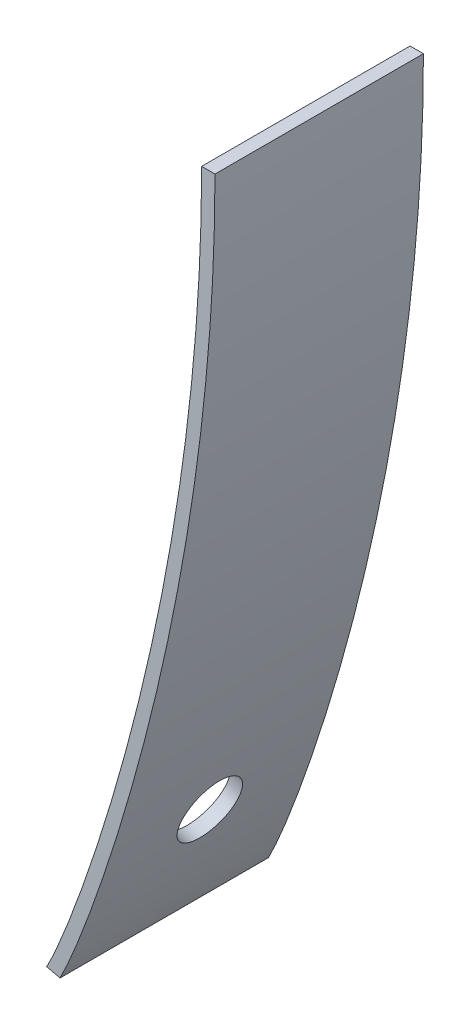
from build123d import *

# Parameters (mm, degrees)
BOSS_EXTRUDE1_DEPTH = 15.875
SKETCH3_R           = 2.38125
CUT_EXTRUDE1_DEPTH  = 22.710547331


with BuildPart() as part:
    # Sketch1 → Boss-Extrude1 (new body)
    with BuildSketch(Plane.XY):
        with BuildLine():
            Line((-1.016, 29.355277439), (0, 29.355277439))
            add(Edge.make_bspline(
                [(0, 29.355277439), (0, 0), (-9.599644928, -25.418345845), (-11.80014336, -29.574736835)],
                knots=[0, 0, 0, 0, 1, 1, 1, 1], degree=3))
            Line((-11.80014336, -29.574736835), (-12.82390686, -29.337045136))
            Line((-12.82390686, -29.337045136), (-12.698066868, -29.099353437))
            add(Edge.make_bspline(
                [(-1.016, 29.355277439), (-1.016, 27.550326556), (-1.090433728, 23.915187486), (-1.504306808, 16.855354767), (-2.457039545, 8.361518974), (-4.099428394, -1.056476565), (-6.042674076, -9.505599636), (-7.747097747, -15.565843862), (-9.061893662, -19.723126975), (-9.998550617, -22.469633369), (-10.860488882, -24.818373274), (-11.495244143, -26.421861441), (-11.9392839, -27.477329912), (-12.237192952, -28.15188839), (-12.451060525, -28.609168554), (-12.602329361, -28.915317146), (-12.664333464, -29.035636411), (-12.698066868, -29.099353437)],
                knots=[0, 0, 0, 0, 0.0625, 0.125, 0.25, 0.375, 0.5, 0.625, 0.6875, 0.75, 0.8125, 0.875, 0.90625, 0.9375, 0.96875, 0.984375, 1, 1, 1, 1], degree=3))
        make_face()
    extrude(amount=BOSS_EXTRUDE1_DEPTH)

    # Sketch3 → Cut-Extrude1 (cut, through all)
    with BuildSketch(Plane(origin=(-9.637227011, -24.424781037, 8.010581608), x_dir=(0, 0, -1), z_dir=(0.937440941, -0.348144342, 0))):
        with Locations((0.073081608, 3.944213504)):
            Circle(SKETCH3_R)
    extrude(amount=-CUT_EXTRUDE1_DEPTH, mode=Mode.SUBTRACT)


solid = part.part
